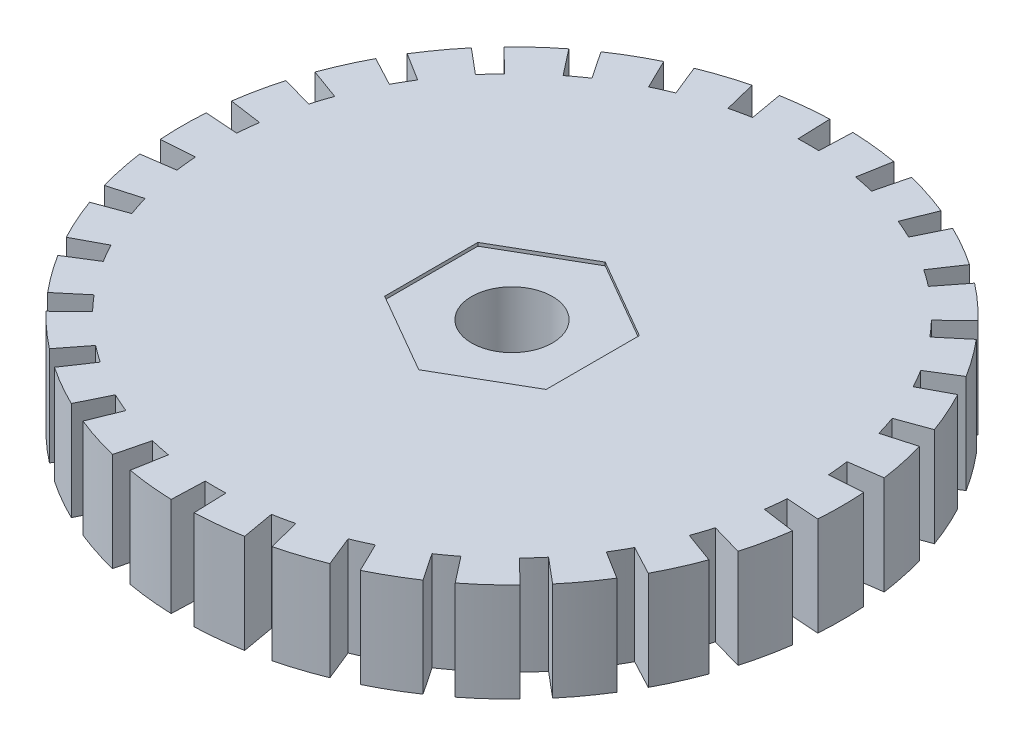
from build123d import *

# Parameters (mm, degrees)
SKETCH1_R           = 1.225
BOSS_EXTRUDE1_DEPTH = 1.9
SKETCH2_R           = 10
BOSS_EXTRUDE2_DEPTH = 2
SKETCH3_R           = 10
SKETCH3_R_2         = 1.3
BOSS_EXTRUDE3_DEPTH = 1
CUT_EXTRUDE1_DEPTH  = 10
CIRPATTERN1_COUNT   = 30


with BuildPart() as part:
    # Sketch1 → Boss-Extrude1 (new body)
    with BuildSketch(Plane(origin=(0, 0, 0), x_dir=(1, 0, 0), z_dir=(0, 1, 0))):
        Polygon((0, -2.829016319), (2.45, -1.41450816), (2.45, 1.41450816), (0, 2.829016319), (-2.45, 1.41450816), (-2.45, -1.41450816), align=None)
        Circle(SKETCH1_R, mode=Mode.SUBTRACT)
    extrude(amount=BOSS_EXTRUDE1_DEPTH)


with BuildPart() as body_2:
    # Sketch2 → Boss-Extrude2 (new body)
    with BuildSketch(Plane(origin=(0, 0, 0), x_dir=(1, 0, 0), z_dir=(0, 1, 0))):
        Circle(SKETCH2_R)
        Polygon((-2.45, -1.41450816), (0, -2.829016319), (2.45, -1.41450816), (2.45, 1.41450816), (0, 2.829016319), (-2.45, 1.41450816), align=None, mode=Mode.SUBTRACT)
    extrude(amount=BOSS_EXTRUDE2_DEPTH)

    # Sketch3 → Boss-Extrude3 (add)
    with BuildSketch(Plane.XZ):
        Circle(SKETCH3_R)
        Circle(SKETCH3_R_2, mode=Mode.SUBTRACT)
    extrude(amount=BOSS_EXTRUDE3_DEPTH)

    # Sketch4 → Cut-Extrude1 (cut)
    with BuildSketch(Plane(origin=(0, 2, 0), x_dir=(1, 0, 0), z_dir=(0, 1, 0))):
        with BuildLine():
            ThreePointArc((0.31409547, -8.994517443), (0, -9), (-0.31409547, -8.994517443))
            Line((-0.31409547, -8.994517443), (-0.348994967, -9.99390827))
            Line((-0.348994967, -9.99390827), (-0.348994967, -10.651767424))
            Line((-0.348994967, -10.651767424), (0.348994967, -10.651767424))
            Line((0.348994967, -10.651767424), (0.348994967, -9.99390827))
            Line((0.348994967, -9.99390827), (0.31409547, -8.994517443))
        make_face()
    cut_extrude1 = extrude(amount=-CUT_EXTRUDE1_DEPTH, mode=Mode.SUBTRACT)

    # CirPattern1: Cut-Extrude1 ×30 about axis
    cirpattern1_axis = Axis((0, 0, 0), (0, 1, 0))
    for i in range(1, CIRPATTERN1_COUNT):
        add(cut_extrude1.rotate(cirpattern1_axis, i * 360 / CIRPATTERN1_COUNT), mode=Mode.SUBTRACT)


solid = Compound([part.part, body_2.part])
